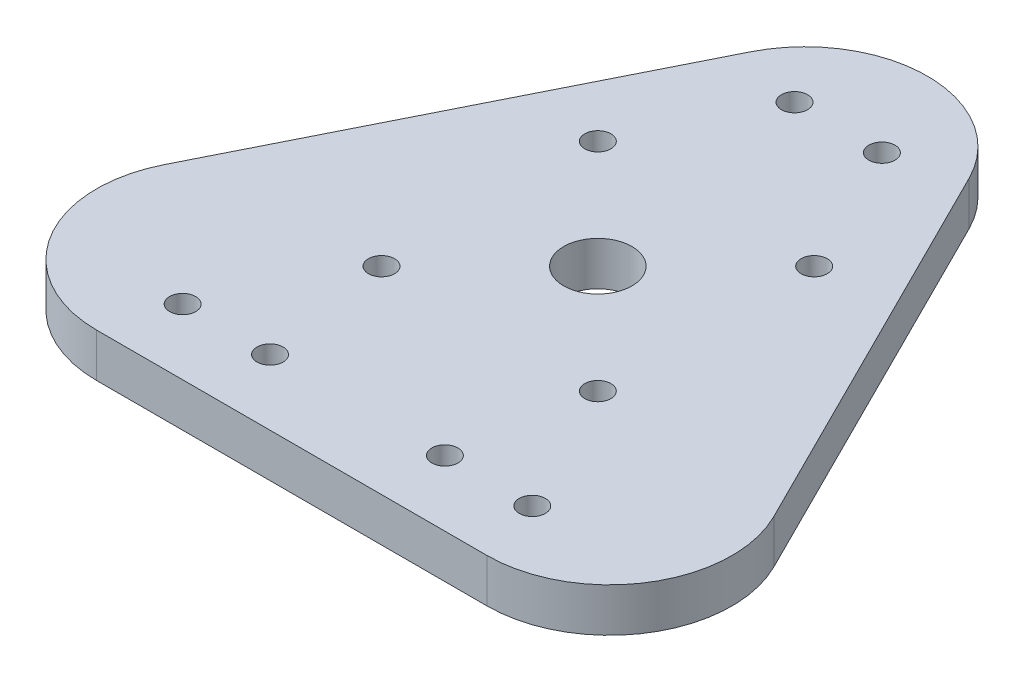
from build123d import *

# Parameters (mm, degrees)
BOSS_EXTRUDE1_DEPTH       = 6.35
F_6_CLEARANCE_HOLE1_D     = 3.7973
FILLET1_R                 = 17.78
F_7_16_20_TAPPED_HOLE1_D  = 9.92124
F_6_CLEARANCE_HOLE2_D     = 3.7973
F_6_CLEARANCE_HOLE2_DEPTH = 6.35


with BuildPart() as part:
    # Sketch1 → Boss-Extrude1 (new body)
    with BuildSketch(Plane(origin=(0, 0, 0), x_dir=(1, 0, 0), z_dir=(0, 1, 0))):
        Polygon((-57.15, 0), (0, 114.3), (57.15, 0), align=None)
    extrude(amount=-BOSS_EXTRUDE1_DEPTH)

    # #6 Clearance Hole1 (through all)
    with Locations(Plane(origin=(0, 0, 0), x_dir=(1, 0, 0), z_dir=(0, 1, 0))):
        with Locations((25.4, 9.525), (12.7, 9.525), (-6.35, 79.375), (6.35, 79.375), (-25.4, 9.525), (-12.7, 9.525)):
            Hole(F_6_CLEARANCE_HOLE1_D / 2)

    # Fillet1
    fillet1_edges = [part.edges().sort_by_distance(p)[0] for p in [
        (-57.15, -3.175, 0),
        (0, -3.175, -114.3),
        (57.15, -3.175, 0),
    ]]
    fillet(fillet1_edges, radius=FILLET1_R)

    # 7/16-20 Tapped Hole1 (through all)
    with Locations(Plane(origin=(0, 0, 0), x_dir=(1, 0, 0), z_dir=(0, 1, 0))):
        with Locations((0, 44.45)):
            Hole(F_7_16_20_TAPPED_HOLE1_D / 2)

    # #6 Clearance Hole2
    with Locations(Plane(origin=(0, 0, 0), x_dir=(1, 0, 0), z_dir=(0, 1, 0))):
        with Locations((-15.715448212, 60.165448212), (15.715448212, 28.734551788), (-15.715448212, 28.734551788), (15.715448212, 60.165448212)):
            Hole(F_6_CLEARANCE_HOLE2_D / 2, depth=F_6_CLEARANCE_HOLE2_DEPTH)


solid = part.part
